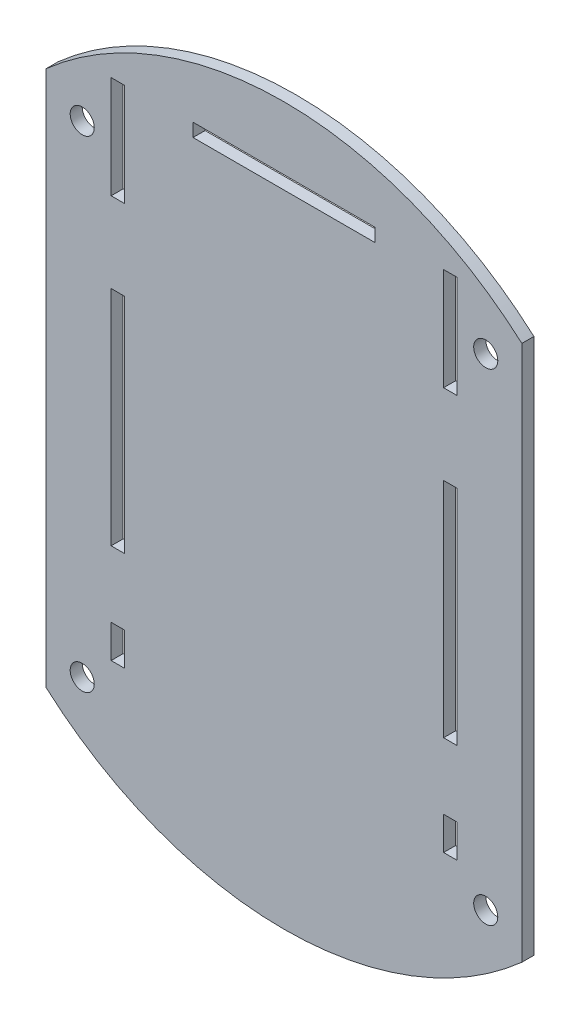
from build123d import *

# Parameters (mm, degrees)
SKIZZE1_R                       = 59.5
AUFSATZ_LINEAR_AUSTRAGEN1_DEPTH = 2
SKIZZE3_R                       = 2
SKIZZE3_W                       = 2.2
SKIZZE3_H                       = 37
SKIZZE3_H_2                     = 17
SKIZZE3_H_3                     = 5.5
SKIZZE3_W_2                     = 30.2
SKIZZE3_H_4                     = 2.2
SKIZZE3_W_3                     = 20
SKIZZE3_H_5                     = 88.994381846
SCHNITT_LINEAR_AUSTRAGEN7_DEPTH = 2


with BuildPart() as part:
    # Skizze1 → Aufsatz-Linear austragen1 (new body)
    with BuildSketch(Plane.XY):
        Circle(SKIZZE1_R)
    extrude(amount=AUFSATZ_LINEAR_AUSTRAGEN1_DEPTH)

    # Skizze3 → Schnitt-Linear austragen7 (cut)
    with BuildSketch(Plane.XY.offset(2)):
        with Locations((-33.5, 40)):
            Circle(SKIZZE3_R)
        with Locations((33.5, 40)):
            Circle(SKIZZE3_R)
        with Locations((33.5, -40)):
            Circle(SKIZZE3_R)
        with Locations((-33.5, -40)):
            Circle(SKIZZE3_R)
        with Locations((-27.6, -0.21138397)):
            Rectangle(SKIZZE3_W, SKIZZE3_H)
        with Locations((27.6, -0.21138397)):
            Rectangle(SKIZZE3_W, SKIZZE3_H)
        with Locations((-27.6, 40.120629313)):
            Rectangle(SKIZZE3_W, SKIZZE3_H_2)
        with Locations((27.6, 40.120629313)):
            Rectangle(SKIZZE3_W, SKIZZE3_H_2)
        with Locations((-27.6, -32.46138397)):
            Rectangle(SKIZZE3_W, SKIZZE3_H_3)
        with Locations((27.6, -32.46138397)):
            Rectangle(SKIZZE3_W, SKIZZE3_H_3)
        with Locations((0, 47.9)):
            Rectangle(SKIZZE3_W_2, SKIZZE3_H_4)
        with Locations((49.5, 0)):
            Rectangle(SKIZZE3_W_3, SKIZZE3_H_5)
        with Locations((-49.5, 0)):
            Rectangle(SKIZZE3_W_3, SKIZZE3_H_5)
    extrude(amount=-SCHNITT_LINEAR_AUSTRAGEN7_DEPTH, mode=Mode.SUBTRACT)


solid = part.part
